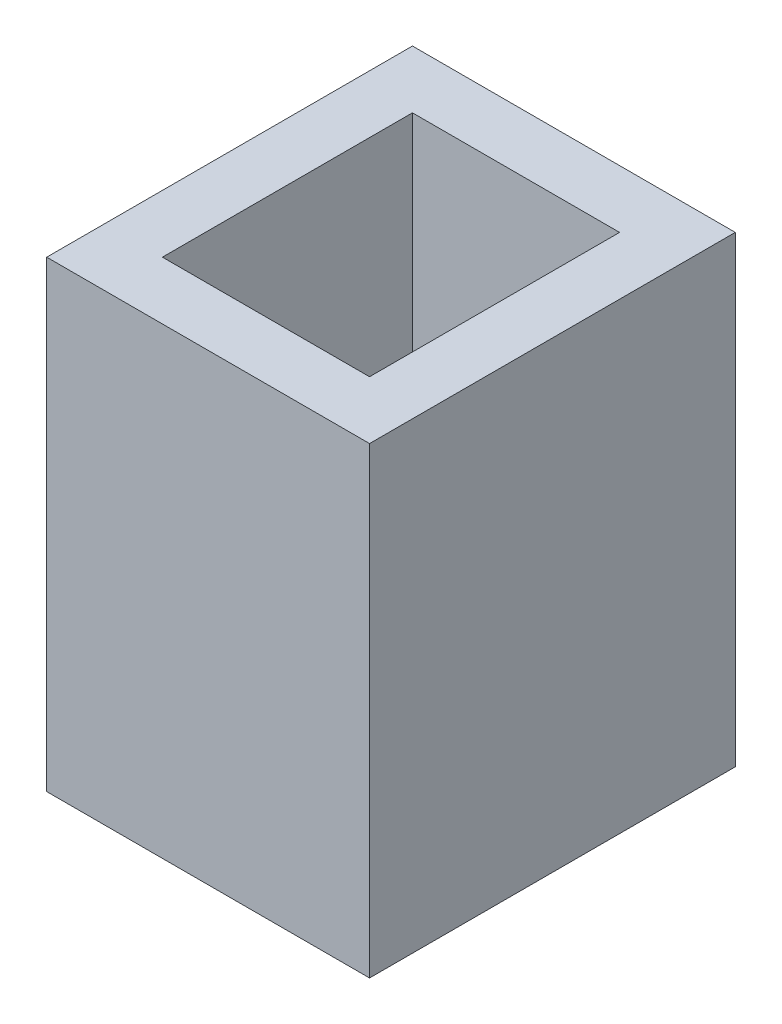
from build123d import *

# Parameters (mm, degrees)
SKETCH1_W           = 17.7165
SKETCH1_H           = 20.07108
SKETCH1_W_2         = 11.3665
SKETCH1_H_2         = 13.72108
BOSS_EXTRUDE1_DEPTH = 25.4


with BuildPart() as part:
    # Sketch1 → Boss-Extrude1 (new body)
    with BuildSketch(Plane(origin=(0, 0, 0), x_dir=(1, 0, 0), z_dir=(0, 1, 0))):
        Rectangle(SKETCH1_W, SKETCH1_H)
        Rectangle(SKETCH1_W_2, SKETCH1_H_2, mode=Mode.SUBTRACT)
    extrude(amount=BOSS_EXTRUDE1_DEPTH)


solid = part.part
